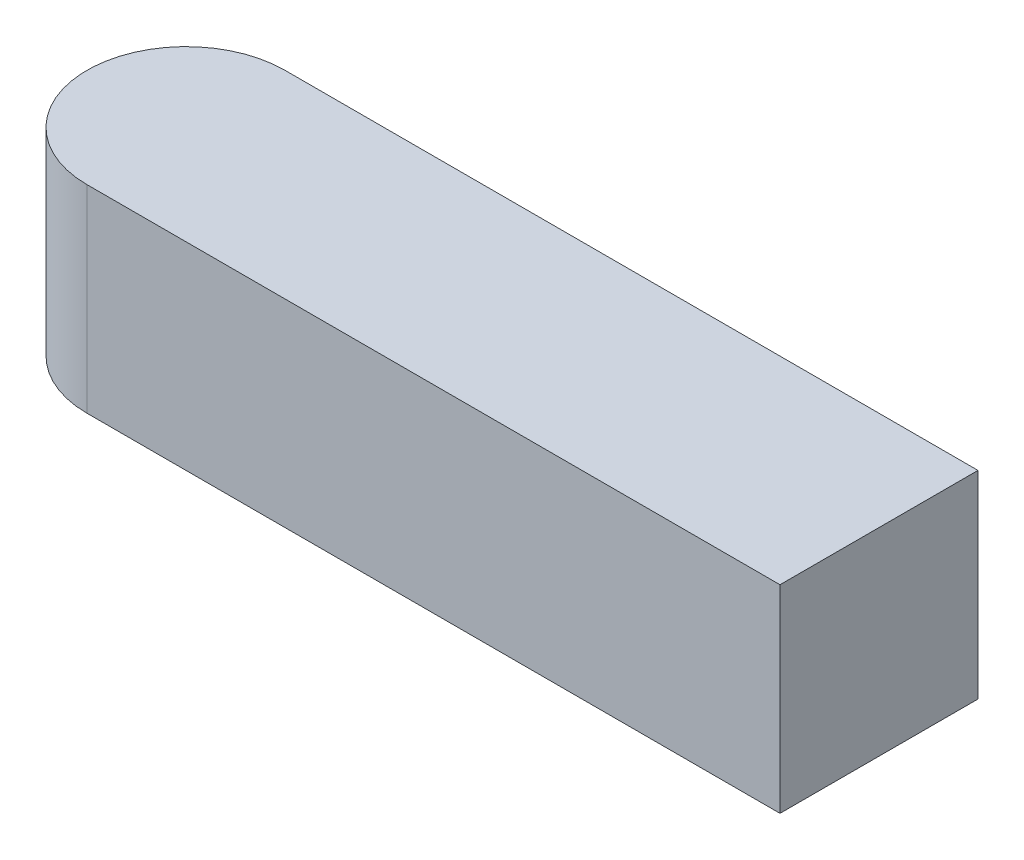
from build123d import *

# Parameters (mm, degrees)
BOSS_EXTRUDE1_DEPTH = 20
SKETCH2_W           = 80
SKETCH2_H           = 20
CUT_EXTRUDE1_DEPTH  = 21


with BuildPart() as part:
    # Sketch1 → Boss-Extrude1 (new body)
    with BuildSketch(Plane(origin=(0, 0, 0), x_dir=(1, 0, 0), z_dir=(0, 1, 0))):
        with BuildLine():
            Line((-70, 10), (70, 10))
            ThreePointArc((70, 10), (80, 0), (70, -10))
            Line((70, -10), (-70, -10))
            ThreePointArc((-70, -10), (-80, 0), (-70, 10))
        make_face()
    extrude(amount=BOSS_EXTRUDE1_DEPTH)

    # Sketch2 → Cut-Extrude1 (cut, through all)
    with BuildSketch(Plane(origin=(0, 20, 0), x_dir=(1, 0, 0), z_dir=(0, 1, 0))):
        with Locations((40, 0)):
            Rectangle(SKETCH2_W, SKETCH2_H)
    extrude(amount=-CUT_EXTRUDE1_DEPTH, mode=Mode.SUBTRACT)


solid = part.part
